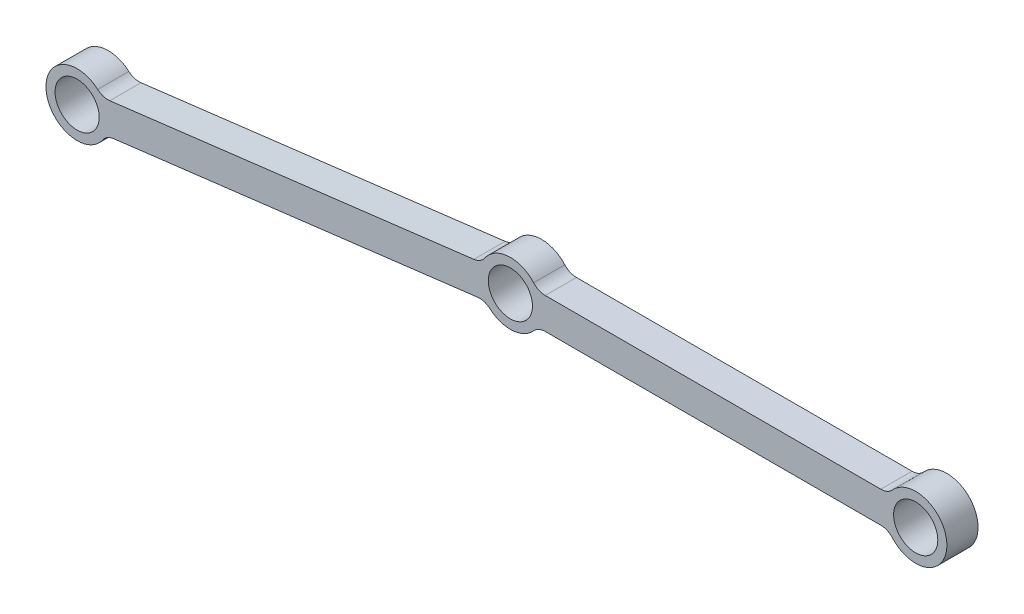
from build123d import *

# Parameters (mm, degrees)
SKETCH1_R           = 4.49961
BOSS_EXTRUDE2_DEPTH = 6.35
FILLET2_R           = 3.175


with BuildPart() as part:
    # Sketch1 → Boss-Extrude2 (new body)
    with BuildSketch(Plane.XY):
        with BuildLine():
            Line((77.050738686, 3.175), (5.499261314, 3.175))
            ThreePointArc((5.499261314, 3.175), (-0.387658226, 6.33815597), (-5.845205819, 2.481142666))
            Line((-5.845205819, 2.481142666), (-83.166017392, -7.012659232))
            ThreePointArc((-83.166017392, -7.012659232), (-94.540020944, -11.608054959), (-82.392147061, -13.315327295))
            Line((-82.392147061, -13.315327295), (-5.071335489, -3.821525397))
            ThreePointArc((-5.071335489, -3.821525397), (0.387658226, -6.33815597), (5.499261314, -3.175))
            Line((5.499261314, -3.175), (77.050738686, -3.175))
            ThreePointArc((77.050738686, -3.175), (88.9, 0), (77.050738686, 3.175))
        make_face()
        Circle(SKETCH1_R, mode=Mode.SUBTRACT)
        with Locations((82.55, 0)):
            Circle(SKETCH1_R, mode=Mode.SUBTRACT)
        with Locations((-88.237352881, -10.834184629)):
            Circle(SKETCH1_R, mode=Mode.SUBTRACT)
    extrude(amount=-BOSS_EXTRUDE2_DEPTH)

    # Fillet2
    fillet2_edges = [part.edges().sort_by_distance(p)[0] for p in [
        (-5.845205819, 2.481142666, -3.175),
        (5.499261314, 3.175, -3.175),
        (77.050738686, 3.175, -3.175),
        (77.050738686, -3.175, -3.175),
        (5.499261314, -3.175, -3.175),
        (-5.071335489, -3.821525397, -3.175),
        (-82.392147061, -13.315327295, -3.175),
        (-83.166017392, -7.012659232, -3.175),
    ]]
    fillet(fillet2_edges, radius=FILLET2_R)


solid = part.part
